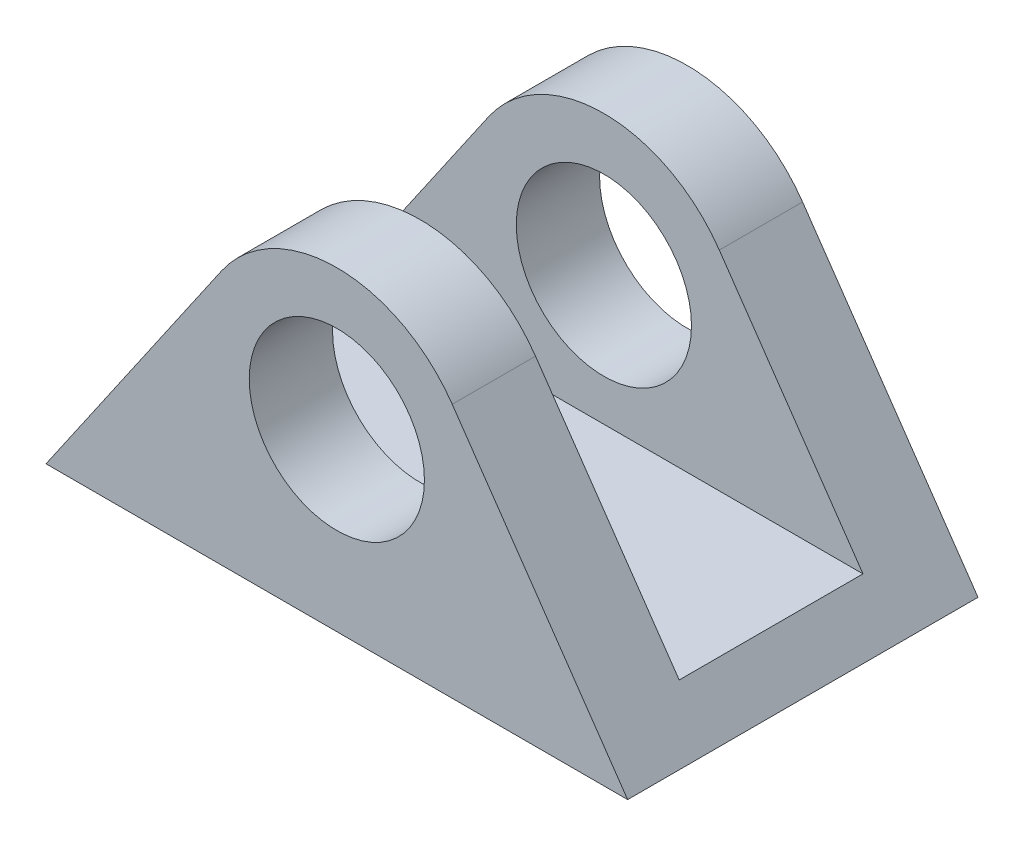
from build123d import *

# Parameters (mm, degrees)
SKETCH1_R               = 5
BOSS_EXTRUDE1_DEPTH     = 20
SKETCH2_W               = 10.491339254
SKETCH2_H               = 19.291026948
CUT_EXTRUDE1_DEPTH      = 17.60180745
CUT_EXTRUDE1_DEPTH_BACK = 17.60180745


with BuildPart() as part:
    # Sketch1 → Boss-Extrude1 (new body)
    with BuildSketch(Plane.XY):
        with BuildLine():
            Line((16.60180745, -10), (6.588404709, 4.537942638))
            ThreePointArc((6.588404709, 4.537942638), (0, 8), (-6.588404709, 4.537942638))
            Line((-6.588404709, 4.537942638), (-16.60180745, -10))
            Line((-16.60180745, -10), (16.60180745, -10))
        make_face()
        Circle(SKETCH1_R, mode=Mode.SUBTRACT)
    extrude(amount=BOSS_EXTRUDE1_DEPTH)

    # Sketch2 → Cut-Extrude1 (cut, two sides)
    with BuildSketch(Plane(origin=(0, 0, 0), x_dir=(0, 0, -1), z_dir=(1, 0, 0))) as cut_extrude1_sk:
        with Locations((-10, 2.276563947)):
            Rectangle(SKETCH2_W, SKETCH2_H)
    extrude(amount=CUT_EXTRUDE1_DEPTH, mode=Mode.SUBTRACT)
    extrude(cut_extrude1_sk.sketch, amount=-CUT_EXTRUDE1_DEPTH_BACK, mode=Mode.SUBTRACT)


solid = part.part
